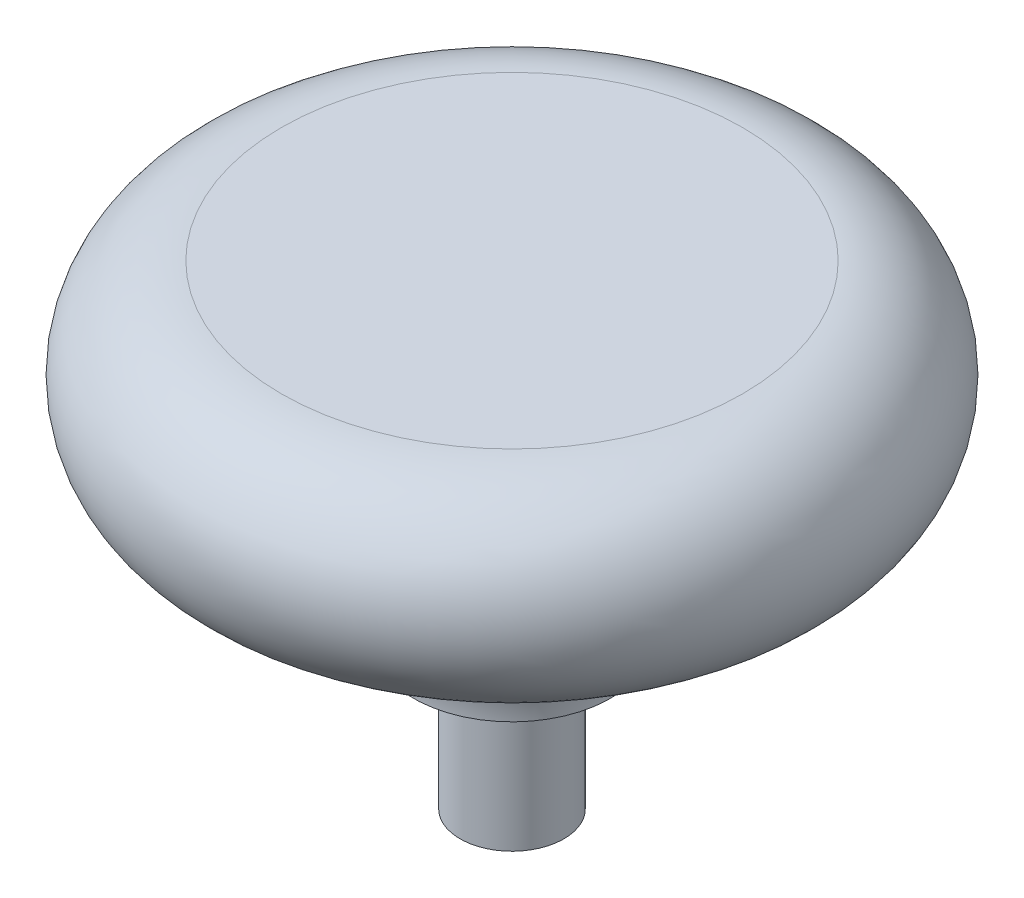
from build123d import *


with BuildPart() as part:
    # Sketch1 → Base-Revolve (revolve)
    with BuildSketch(Plane.XY):
        with BuildLine():
            Line((0, 0), (0, 22.875))
            Line((0, 22.875), (11.1125, 22.875))
            ThreePointArc((11.1125, 22.875), (15.875, 18.1125), (11.1125, 13.35))
            ThreePointArc((11.1125, 13.35), (6.622371939, 11.490128061), (4.7625, 7))
            Line((4.7625, 7), (2.5, 7))
            Line((2.5, 7), (2.5, 0))
            Line((2.5, 0), (0, 0))
        make_face()
    revolve(axis=Axis((0, 0, 0), (0, 1, 0)))


solid = part.part
